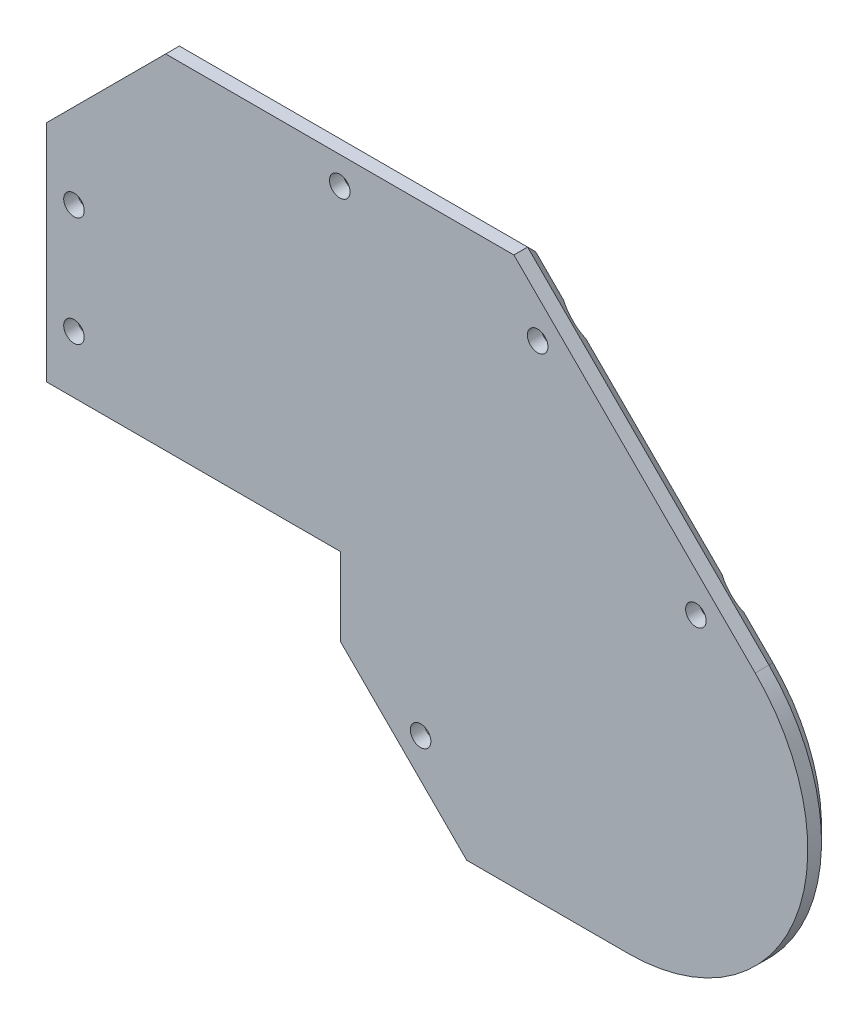
from build123d import *

# Parameters (mm, degrees)
RESSALTO_EXTRUS_O1_DEPTH = 48
ESBO_O12_R               = 1.5
CORTE_EXTRUS_O10_DEPTH   = 10
ESBO_O13_R               = 1.5
CORTE_EXTRUS_O11_DEPTH   = 10
ESBO_O14_R               = 1.5
CORTE_EXTRUS_O12_DEPTH   = 10
ESBO_O15_R               = 1.5
CORTE_EXTRUS_O13_DEPTH   = 10
CORTE_EXTRUS_O14_DEPTH   = 10
ESBO_O17_R               = 4
ESBO_O17_W               = 2.8
ESBO_O17_H               = 2.8
RESSALTO_EXTRUS_O2_DEPTH = 4
ESBO_O18_R               = 1.5
RESSALTO_EXTRUS_O3_DEPTH = 4
CHANFRO1_SIZE            = 2
CORTE_EXTRUS_O15_DEPTH   = 48
ESBO_O20_R               = 3
CORTE_EXTRUS_O16_DEPTH   = 2


with BuildPart() as part:
    # Model → Ressalto-extrusão1 (new body)
    with BuildSketch(Plane.XY):
        with BuildLine():
            Line((-0.7, 0), (39, 0))
            Line((39, 0), (39.7, 0))
            Line((39.7, 0), (39.7, -11.380317396))
            Line((39.7, -11.380317396), (50.182424304, -21.8627417))
            Line((50.182424304, -21.8627417), (58.119682605, -29.8))
            Line((58.119682605, -29.8), (81.7, -29.8))
            ThreePointArc((81.7, -29.8), (105.905643752, -13.626305928), (100.226197667, 14.926197667))
            Line((100.226197667, 14.926197667), (65.00338056, 50.149014774))
            Line((65.00338056, 50.149014774), (50.111140335, 50.149014774))
            Line((50.111140335, 50.149014774), (14.181595121, 50.149014774))
            Line((14.181595121, 50.149014774), (-3.2, 32.767419653))
            Line((-3.2, 32.767419653), (-3.2, 5))
            Line((-3.2, 5), (-3.2, 0))
            Line((-3.2, 0), (-0.7, 0))
        make_face()
        with BuildLine():
            Line((-0.7, 2.5), (39, 2.5))
            Line((39, 2.5), (39.7, 2.5))
            Line((39.7, 2.5), (42.2, 2.5))
            Line((42.2, 2.5), (42.2, -10.34478349))
            Line((42.2, -10.34478349), (51.950191257, -20.094974747))
            Line((51.950191257, -20.094974747), (59.15521651, -27.3))
            Line((59.15521651, -27.3), (81.7, -27.3))
            ThreePointArc((81.7, -27.3), (103.595944921, -12.669597347), (98.458430714, 13.158430714))
            Line((98.458430714, 13.158430714), (63.967846654, 47.649014774))
            Line((63.967846654, 47.649014774), (50.111140335, 47.649014774))
            Line((50.111140335, 47.649014774), (15.217129027, 47.649014774))
            Line((15.217129027, 47.649014774), (-0.7, 31.731885747))
            Line((-0.7, 31.731885747), (-0.7, 2.5))
        make_face(mode=Mode.SUBTRACT)
    extrude(amount=RESSALTO_EXTRUS_O1_DEPTH)

    # Esboço12 → Corte-extrusão10 (cut)
    with BuildSketch(Plane(origin=(57.576197667, 57.576197667, 0), x_dir=(0, 0, -1), z_dir=(0.707106781, 0.707106781, 0))):
        with Locations((-44, -19.409915607)):
            Circle(ESBO_O12_R)
        with Locations((-44, -51.409915607)):
            Circle(ESBO_O12_R)
    extrude(amount=-CORTE_EXTRUS_O10_DEPTH, mode=Mode.SUBTRACT)

    # Esboço13 → Corte-extrusão11 (cut)
    with BuildSketch(Plane(origin=(0, 50.149014774, 0), x_dir=(1, 0, 0), z_dir=(0, 1, 0))):
        with Locations((39.59248784, -44)):
            Circle(ESBO_O13_R)
    extrude(amount=-CORTE_EXTRUS_O11_DEPTH, mode=Mode.SUBTRACT)

    # Esboço14 → Corte-extrusão12 (cut)
    with BuildSketch(Plane.ZY.offset(3.2)):
        with Locations((44, 24.383709827)):
            Circle(ESBO_O14_R)
        with Locations((44, 8.383709827)):
            Circle(ESBO_O14_R)
    extrude(amount=-CORTE_EXTRUS_O12_DEPTH, mode=Mode.SUBTRACT)

    # Esboço15 → Corte-extrusão13 (cut)
    with BuildSketch(Plane(origin=(14.159841302, 14.159841302, 0), x_dir=(0, 0, 1), z_dir=(-0.707106781, -0.707106781, 0))):
        with Locations((44, -48.648946546)):
            Circle(ESBO_O15_R)
    extrude(amount=-CORTE_EXTRUS_O13_DEPTH, mode=Mode.SUBTRACT)

    # Esboço16 → Corte-extrusão14 (cut)
    with BuildSketch(Plane.XY.offset(48)):
        Polygon((39.7, 0), (39.7, -2), (42.2, -2), (42.2, 2.5), (-0.7, 2.5), (-0.7, 0), align=None)
    extrude(amount=-CORTE_EXTRUS_O14_DEPTH, mode=Mode.SUBTRACT)

    # Esboço17 → Ressalto-extrusão2 (add)
    with BuildSketch(Plane(origin=(0, 0, 0), x_dir=(-1, 0, 0), z_dir=(0, 0, -1))):
        with Locations((-91.100070488, 18.395470597)):
            Circle(ESBO_O17_R)
        with Locations((-91.100070488, 18.395470597)):
            Rectangle(ESBO_O17_W, ESBO_O17_H, mode=Mode.SUBTRACT)
        with Locations((-68.47265349, 41.022887595)):
            Circle(ESBO_O17_R)
        with Locations((-68.47265349, 41.022887595)):
            Rectangle(ESBO_O17_W, ESBO_O17_H, mode=Mode.SUBTRACT)
        with Locations((-39.59248784, 46.149014774)):
            Circle(ESBO_O17_R)
        with Locations((-39.59248784, 46.149014774)):
            Rectangle(ESBO_O17_W, ESBO_O17_H, mode=Mode.SUBTRACT)
        with Locations((-0.8, 24.383709827)):
            Circle(ESBO_O17_R)
        with Locations((-0.8, 24.383709827)):
            Rectangle(ESBO_O17_W, ESBO_O17_H, mode=Mode.SUBTRACT)
        with Locations((-0.8, 8.383709827)):
            Circle(ESBO_O17_R)
        with Locations((-0.8, 8.383709827)):
            Rectangle(ESBO_O17_W, ESBO_O17_H, mode=Mode.SUBTRACT)
        with Locations((-51.388268427, -17.411731573)):
            Circle(ESBO_O17_R)
        with Locations((-51.388268427, -17.411731573)):
            Rectangle(ESBO_O17_W, ESBO_O17_H, mode=Mode.SUBTRACT)
    extrude(amount=-RESSALTO_EXTRUS_O2_DEPTH)

    # Esboço18 → Ressalto-extrusão3 (add)
    with BuildSketch(Plane(origin=(0, 0, 0), x_dir=(-1, 0, 0), z_dir=(0, 0, -1))):
        with BuildLine():
            Line((-65.00338056, 50.149014774), (-14.181595121, 50.149014774))
            Line((-14.181595121, 50.149014774), (3.2, 32.767419653))
            Line((3.2, 32.767419653), (3.2, 0))
            Line((3.2, 0), (-39.7, 0))
            Line((-39.7, 0), (-39.7, -11.380317396))
            Line((-39.7, -11.380317396), (-58.119682605, -29.8))
            Line((-58.119682605, -29.8), (-81.7, -29.8))
            ThreePointArc((-81.7, -29.8), (-105.905643752, -13.626305928), (-100.226197667, 14.926197667))
            Line((-100.226197667, 14.926197667), (-65.00338056, 50.149014774))
        make_face()
        with Locations((-91.568699638, 17.926841447)):
            Circle(ESBO_O18_R, mode=Mode.SUBTRACT)
        with Locations((-68.47265349, 41.022887595)):
            Circle(ESBO_O18_R, mode=Mode.SUBTRACT)
        with Locations((-39.59248784, 46.149014774)):
            Circle(ESBO_O18_R, mode=Mode.SUBTRACT)
        with Locations((-0.8, 24.383709827)):
            Circle(ESBO_O18_R, mode=Mode.SUBTRACT)
        with Locations((-51.388268427, -17.411731573)):
            Circle(ESBO_O18_R, mode=Mode.SUBTRACT)
        with Locations((-0.8, 8.383709827)):
            Circle(ESBO_O18_R, mode=Mode.SUBTRACT)
    extrude(amount=RESSALTO_EXTRUS_O3_DEPTH)

    # Chanfro1
    chanfro1_edges = [part.edges().sort_by_distance(p)[0] for p in [
        (82.614789114, 32.53760622, -4),
        (105.905643752, -13.626305928, -4),
        (69.909841302, -29.8, -4),
        (48.909841302, -20.590158698, -4),
        (39.7, -5.690158698, -4),
        (18.25, 0, -4),
        (-3.2, 16.383709827, -4),
        (5.49079756, 41.458217213, -4),
        (39.59248784, 50.149014774, -4),
    ]]
    chamfer(chanfro1_edges, length=CHANFRO1_SIZE)

    # Esboço19 → Corte-extrusão15 (cut)
    with BuildSketch(Plane.XY.offset(48)):
        with BuildLine():
            Line((65.00338056, 50.149014774), (14.181595121, 50.149014774))
            Line((14.181595121, 50.149014774), (-3.2, 32.767419653))
            Line((-3.2, 32.767419653), (-3.2, 0))
            Line((-3.2, 0), (39.7, 0))
            Line((39.7, 0), (39.7, -11.380317396))
            Line((39.7, -11.380317396), (58.119682605, -29.8))
            Line((58.119682605, -29.8), (81.7, -29.8))
            ThreePointArc((81.7, -29.8), (105.905643752, -13.626305928), (100.226197667, 14.926197667))
            Line((100.226197667, 14.926197667), (65.00338056, 50.149014774))
        make_face()
    extrude(amount=-CORTE_EXTRUS_O15_DEPTH, mode=Mode.SUBTRACT)

    # Esboço20 → Corte-extrusão16 (cut)
    with BuildSketch(Plane(origin=(0, 0, -4), x_dir=(-1, 0, 0), z_dir=(0, 0, -1))):
        with Locations((-0.8, 24.383709827)):
            Circle(ESBO_O20_R)
        with Locations((-0.8, 8.383709827)):
            Circle(ESBO_O20_R)
        with Locations((-39.59248784, 46.149014774)):
            Circle(ESBO_O20_R)
        with Locations((-68.47265349, 41.022887595)):
            Circle(ESBO_O20_R)
        with Locations((-51.388268427, -17.411731573)):
            Circle(ESBO_O20_R)
        with Locations((-91.568699638, 17.926841447)):
            Circle(ESBO_O20_R)
    extrude(amount=-CORTE_EXTRUS_O16_DEPTH, mode=Mode.SUBTRACT)


solid = part.part
